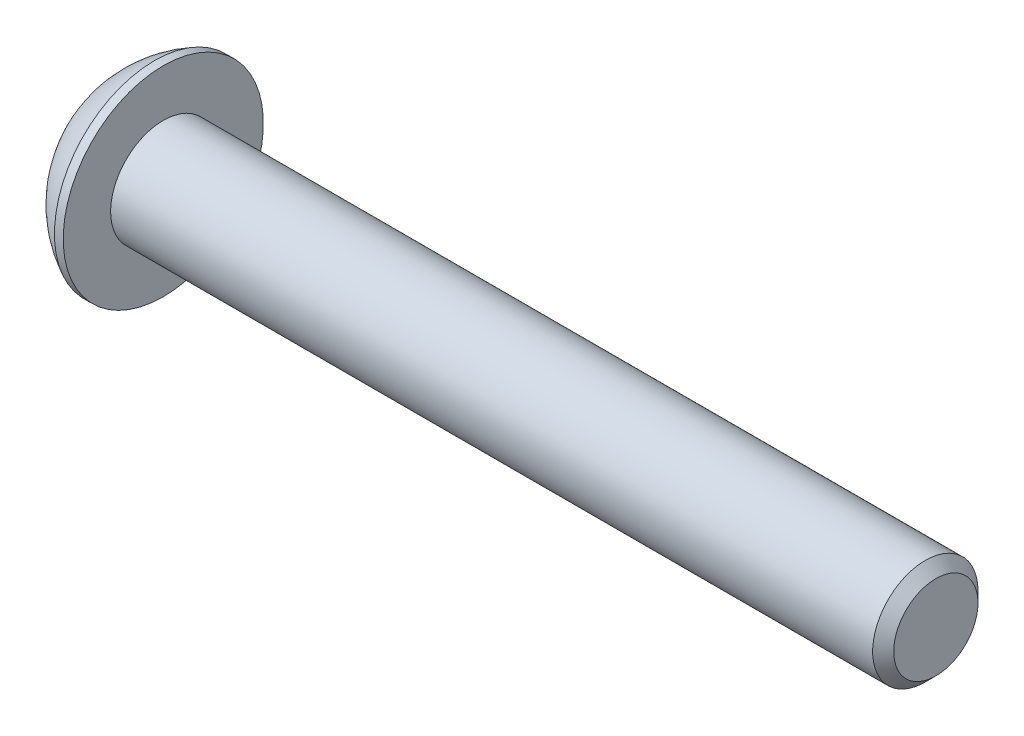
from build123d import *

# Parameters (mm, degrees)
SKETCH2_R           = 1.5
BOSS_EXTRUDE1_DEPTH = 22
CHAMFER1_SIZE       = 0.3
CUT_EXTRUDE1_DEPTH  = 1.2
SKETCH8_R           = 1.204700538
CUT_EXTRUDE2_DEPTH  = 1
CUT_EXTRUDE2_TAPER  = 45


with BuildPart() as part:
    # Sketch2 → Boss-Extrude1 (new body)
    with BuildSketch(Plane(origin=(0, 0, 0), x_dir=(0, 0, -1), z_dir=(1, 0, 0))):
        Circle(SKETCH2_R)
    extrude(amount=-BOSS_EXTRUDE1_DEPTH)

    # Chamfer1
    chamfer1_edges = [part.edges().sort_by_distance(p)[0] for p in [
        (0, 0, 1.5),
    ]]
    chamfer(chamfer1_edges, length=CHAMFER1_SIZE)

    # Sketch6 → Revolve1 (revolve)
    with BuildSketch(Plane.XY):
        with BuildLine():
            Line((-23.65, 0), (-23.65, 1.5))
            ThreePointArc((-23.65, 1.5), (-23.055944823, 2.284868705), (-22.25, 2.85))
            Line((-22.25, 2.85), (-22, 2.85))
            Line((-22, 2.85), (-22, 0))
            Line((-22, 0), (-23.65, 0))
        make_face()
    revolve(axis=Axis((-22, 0, 0), (1, 0, 0)))

    # Sketch7 → Cut-Extrude1 (cut)
    with BuildSketch(Plane.ZY.offset(23.65)):
        Polygon((0, 1.154700538), (-1, 0.577350269), (-1, -0.577350269), (0, -1.154700538), (1, -0.577350269), (1, 0.577350269), align=None)
    extrude(amount=-CUT_EXTRUDE1_DEPTH, mode=Mode.SUBTRACT)

    # Sketch8 → Cut-Extrude2 (cut)
    with BuildSketch(Plane.ZY.offset(23.65)):
        Circle(SKETCH8_R)
    extrude(amount=-CUT_EXTRUDE2_DEPTH, taper=CUT_EXTRUDE2_TAPER, mode=Mode.SUBTRACT)


solid = part.part
